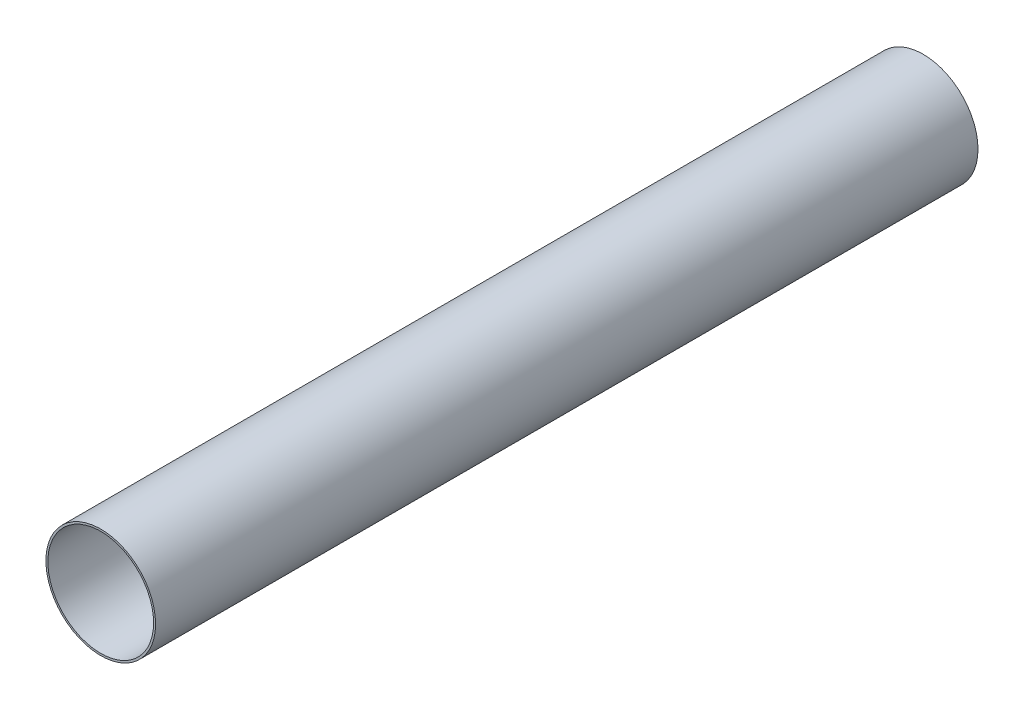
from build123d import *

# Parameters (mm, degrees)
PIPESKETCH_R    = 177.8
PIPESKETCH_R_2  = 171.45
EXTRUSION_DEPTH = 2666.6


with BuildPart() as part:
    # PipeSketch → Extrusion (new body)
    with BuildSketch(Plane.XY):
        Circle(PIPESKETCH_R)
        Circle(PIPESKETCH_R_2, mode=Mode.SUBTRACT)
    extrude(amount=EXTRUSION_DEPTH)


solid = part.part
